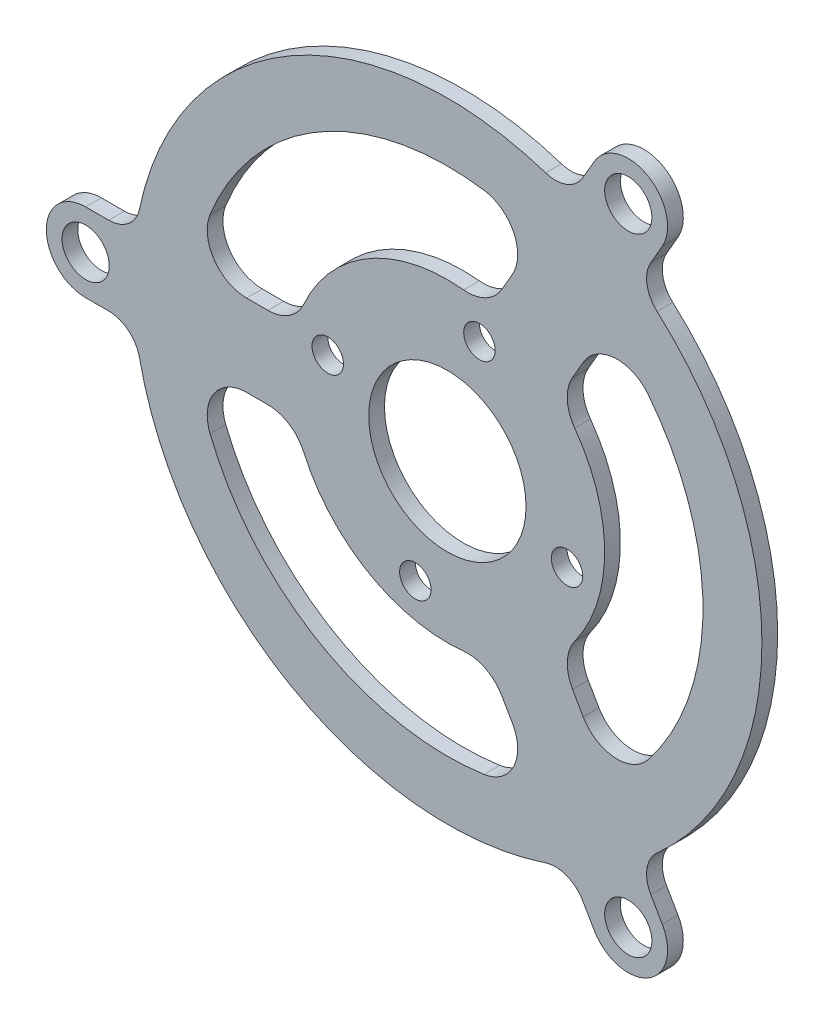
from build123d import *

# Parameters (mm, degrees)
SKETCH1_R                = 40
BOSS_EXTRUDE1_DEPTH      = 2
SKETCH4_R                = 3
BOSS_EXTRUDE3_DEPTH      = 2
FILLET2_R                = 4
CIRPATTERN2_COUNT        = 3
FILLET2_OF_CIRPATTERN2_R = 4
SKETCH5_R                = 10
CUT_EXTRUDE1_DEPTH       = 8
CUT_EXTRUDE3_DEPTH       = 15
FILLET3_R                = 5
CIRPATTERN4_COUNT        = 3
FILLET3_OF_CIRPATTERN4_R = 5
SKETCH6_R                = 2
CUT_EXTRUDE4_DEPTH       = 10
CIRPATTERN5_COUNT        = 4


with BuildPart() as part:
    # Sketch1 → Boss-Extrude1 (new body)
    with BuildSketch(Plane.XY):
        Circle(SKETCH1_R)
    extrude(amount=BOSS_EXTRUDE1_DEPTH)

    # Sketch4 → Boss-Extrude3 (add)
    with BuildSketch(Plane(origin=(0, 0, 0), x_dir=(-1, 0, 0), z_dir=(0, 0, -1))):
        with BuildLine():
            Line((-15.513007814, 36.869317712), (-18.669872981, 42.337168574))
            ThreePointArc((-18.669872981, 42.337168574), (-25.5, 44.167295593), (-27.330127019, 37.337168574))
            Line((-27.330127019, 37.337168574), (-24.173261852, 31.869317712))
            ThreePointArc((-24.173261852, 31.869317712), (-20, 34.641016151), (-15.513007814, 36.869317712))
        make_face()
        with Locations((-23, 39.837168574)):
            Circle(SKETCH4_R, mode=Mode.SUBTRACT)
    boss_extrude3 = extrude(amount=-BOSS_EXTRUDE3_DEPTH)

    # Fillet2
    fillet2_edges = [part.edges().sort_by_distance(p)[0] for p in [
        (24.173261852, 31.869317712, 1),
        (15.513007814, 36.869317712, 1),
    ]]
    fillet(fillet2_edges, radius=FILLET2_R)

    # CirPattern2: Boss-Extrude3 ×3 about axis
    cirpattern2_axis = Axis((0, 0, 2), (0, 0, -1))
    for i in range(1, CIRPATTERN2_COUNT):
        add(boss_extrude3.rotate(cirpattern2_axis, i * 360 / CIRPATTERN2_COUNT))

    # Fillet2 of CirPattern2
    fillet2_of_cirpattern2_edges = [part.edges().sort_by_distance(p)[0] for p in [
        (15.513007814, -36.869317712, 1),
        (24.173261852, -31.869317712, 1),
        (-39.686269666, 5, 1),
        (-39.686269666, -5, 1),
    ]]
    fillet(fillet2_of_cirpattern2_edges, radius=FILLET2_OF_CIRPATTERN2_R)

    # Sketch5 → Cut-Extrude1 (cut)
    with BuildSketch(Plane(origin=(0, 0, 0), x_dir=(-1, 0, 0), z_dir=(0, 0, -1))):
        Circle(SKETCH5_R)
    extrude(amount=-CUT_EXTRUDE1_DEPTH, mode=Mode.SUBTRACT)

    # Sketch7 → Cut-Extrude3 (cut)
    with BuildSketch(Plane(origin=(0, 0, 0), x_dir=(-1, 0, 0), z_dir=(0, 0, -1))):
        with BuildLine():
            ThreePointArc((-5.156603958, 19.323804895), (10, 17.320508076), (19.313207916, 5.196152423))
            Line((19.313207916, 5.196152423), (32.081926376, 5.196152423))
            ThreePointArc((32.081926376, 5.196152423), (16.25, 28.145825623), (-11.540963188, 30.381839455))
            Line((-11.540963188, 30.381839455), (-5.156603958, 19.323804895))
        make_face()
    cut_extrude3 = extrude(amount=-CUT_EXTRUDE3_DEPTH, mode=Mode.SUBTRACT)

    # Fillet3
    fillet3_edges = [part.edges().sort_by_distance(p)[0] for p in [
        (-32.081926376, 5.196152423, 1),
        (-19.313207916, 5.196152423, 1),
        (5.156603958, 19.323804895, 1),
        (11.540963188, 30.381839455, 1),
    ]]
    fillet(fillet3_edges, radius=FILLET3_R)

    # CirPattern4: Cut-Extrude3 ×3 about axis
    cirpattern4_axis = Axis((0, 0, 2), (0, 0, -1))
    for i in range(1, CIRPATTERN4_COUNT):
        add(cut_extrude3.rotate(cirpattern4_axis, i * 360 / CIRPATTERN4_COUNT), mode=Mode.SUBTRACT)

    # Fillet3 of CirPattern4
    fillet3_of_cirpattern4_edges = [part.edges().sort_by_distance(p)[0] for p in [
        (20.540963188, 25.185687033, 1),
        (14.156603958, 14.127652472, 1),
        (14.156603958, -14.127652472, 1),
        (20.540963188, -25.185687033, 1),
        (11.540963188, -30.381839455, 1),
        (5.156603958, -19.323804895, 1),
        (-19.313207916, -5.196152423, 1),
        (-32.081926376, -5.196152423, 1),
    ]]
    fillet(fillet3_of_cirpattern4_edges, radius=FILLET3_OF_CIRPATTERN4_R)

    # Sketch6 → Cut-Extrude4 (cut)
    with BuildSketch(Plane(origin=(0, 0, 0), x_dir=(-1, 0, 0), z_dir=(0, 0, -1))):
        with Locations((4.07639996, -15.213331764)):
            Circle(SKETCH6_R)
    cut_extrude4 = extrude(amount=-CUT_EXTRUDE4_DEPTH, mode=Mode.SUBTRACT)

    # CirPattern5: Cut-Extrude4 ×4 about axis
    cirpattern5_axis = Axis((0, 0, 8), (0, 0, -1))
    for i in range(1, CIRPATTERN5_COUNT):
        add(cut_extrude4.rotate(cirpattern5_axis, i * 360 / CIRPATTERN5_COUNT), mode=Mode.SUBTRACT)


solid = part.part
